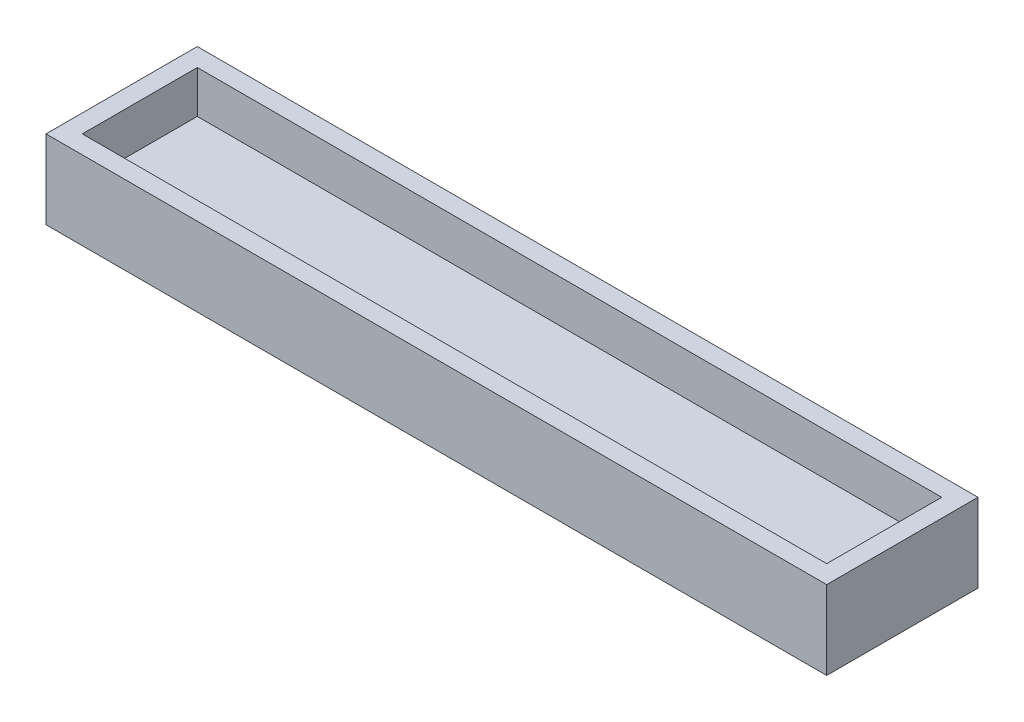
from build123d import *

# Parameters (mm, degrees)
SKETCH1_W           = 123
SKETCH1_H           = 19
BOSS_EXTRUDE1_DEPTH = 6
SKETCH2_W           = 129
SKETCH2_H           = 25
SKETCH2_W_2         = 123
SKETCH2_H_2         = 19
BOSS_EXTRUDE3_DEPTH = 13


with BuildPart() as part:
    # Sketch1 → Boss-Extrude1 (new body)
    with BuildSketch(Plane(origin=(0, 0, 0), x_dir=(1, 0, 0), z_dir=(0, 1, 0))):
        with Locations((61.5, 9.5)):
            Rectangle(SKETCH1_W, SKETCH1_H)
    extrude(amount=BOSS_EXTRUDE1_DEPTH)

    # Sketch2 → Boss-Extrude3 (add)
    with BuildSketch(Plane.XZ):
        with Locations((61.5, -9.5)):
            Rectangle(SKETCH2_W, SKETCH2_H)
        with Locations((61.5, -9.5)):
            Rectangle(SKETCH2_W_2, SKETCH2_H_2, mode=Mode.SUBTRACT)
    extrude(amount=-BOSS_EXTRUDE3_DEPTH)


solid = part.part
